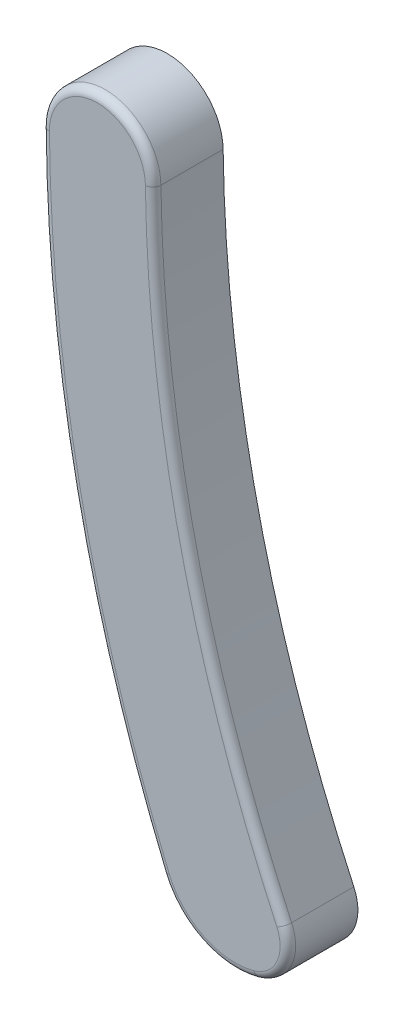
from build123d import *

# Parameters (mm, degrees)
EXTRUDE1_DEPTH = 4.5
FILLET1_R      = 0.5


with BuildPart() as part:
    # Sketch1 → Extrude1 (new body)
    with BuildSketch(Plane.XY):
        with BuildLine():
            ThreePointArc((-0.746559936, 18.690444938), (1.504276061, -0.190220828), (7.658793849, -18.180988273))
            ThreePointArc((7.658793849, -18.180988273), (7.66003149, -20.530722722), (5.866174119, -22.048395034))
            ThreePointArc((5.866174119, -22.048395034), (2.294255729, -21.716159254), (-0.170136467, -19.109292801))
            ThreePointArc((-0.170136467, -19.109292801), (-5.883088092, -0.625489951), (-7.918665293, 18.613668282))
            ThreePointArc((-7.918665293, 18.613668282), (-4.370906261, 22.229264553), (-0.746559936, 18.690444938))
        make_face()
    extrude(amount=EXTRUDE1_DEPTH)

    # Fillet1
    fillet1_edges = [part.edges().sort_by_distance(p)[0] for p in [
        (2.294255729, -21.716159254, 4.5),
        (7.66003149, -20.530722722, 4.5),
        (1.504276061, -0.190220828, 4.5),
        (-4.370906261, 22.229264553, 4.5),
        (-5.883088092, -0.625489951, 4.5),
    ]]
    fillet(fillet1_edges, radius=FILLET1_R)


solid = part.part
